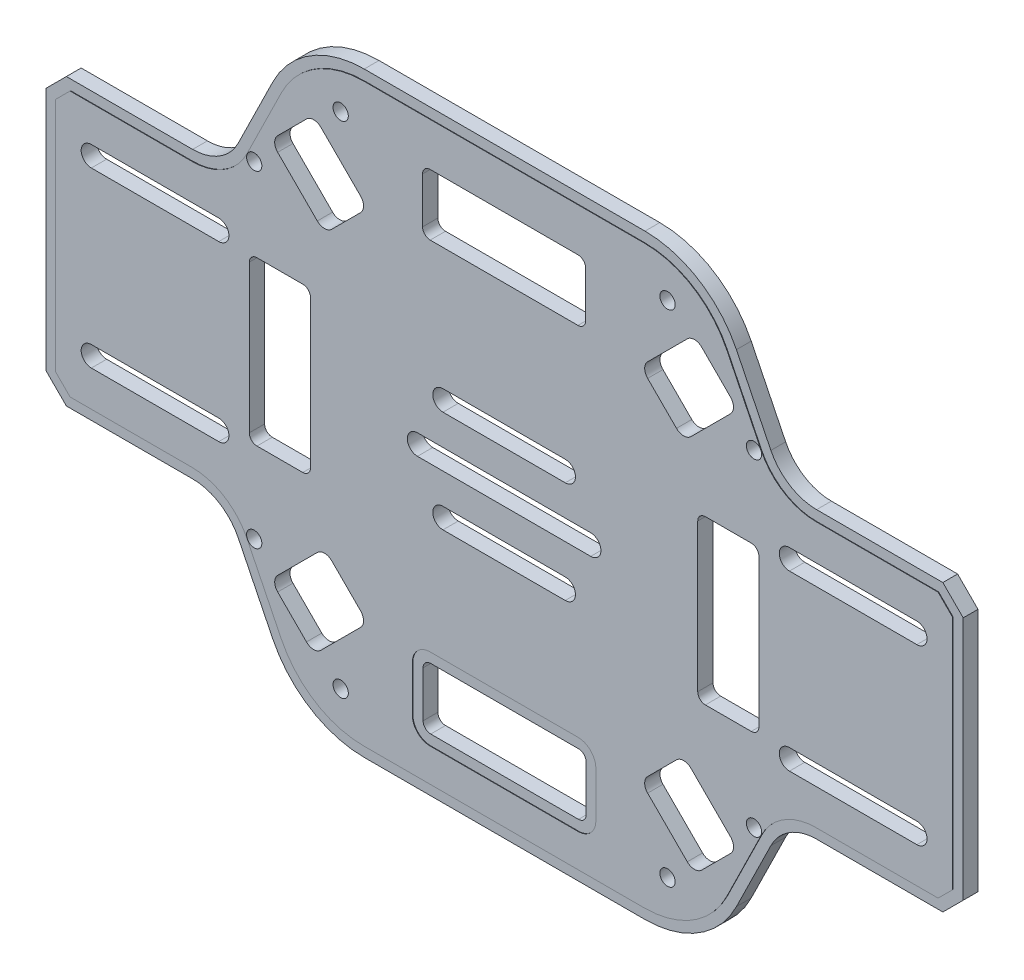
from build123d import *

# Parameters (mm, degrees)
SALIENTE_EXTRUIR1_DEPTH = 1.5
CHAFL_N1_SIZE           = 4
CORTAR_EXTRUIR1_DEPTH   = 0.1
CORTAR_EXTRUIR2_DEPTH   = 0.1
CROQUIS4_R              = 1.5
CORTAR_EXTRUIR3_DEPTH   = 24.1
CROQUIS5_R              = 1.5
CORTAR_EXTRUIR4_DEPTH   = 24.1
CORTAR_EXTRUIR5_DEPTH   = 24.1


with BuildPart() as part:
    # Croquis1 → Saliente-Extruir1 (new body, symmetric)
    with BuildSketch(Plane.XY):
        with BuildLine():
            Line((0, -28), (0, 28))
            Line((0, 28), (28.774108591, 28))
            ThreePointArc((28.774108591, 28), (34.059372749, 29.510831444), (37.747608252, 33.586803445))
            Line((37.747608252, 33.586803445), (44.504783496, 47.326393109))
            ThreePointArc((44.504783496, 47.326393109), (51.881254502, 55.478337112), (62.451782819, 58.5))
            Line((62.451782819, 58.5), (117.548217181, 58.5))
            ThreePointArc((117.548217181, 58.5), (128.118745498, 55.478337112), (135.495216504, 47.326393109))
            Line((135.495216504, 47.326393109), (142.252391748, 33.586803445))
            ThreePointArc((142.252391748, 33.586803445), (145.940627251, 29.510831444), (151.225891409, 28))
            Line((151.225891409, 28), (180, 28))
            Line((180, 28), (180, -28))
            Line((180, -28), (151.225891409, -28))
            ThreePointArc((151.225891409, -28), (145.940627251, -29.510831444), (142.252391748, -33.586803445))
            Line((142.252391748, -33.586803445), (135.495216504, -47.326393109))
            ThreePointArc((135.495216504, -47.326393109), (128.118745498, -55.478337112), (117.548217181, -58.5))
            Line((117.548217181, -58.5), (62.451782819, -58.5))
            ThreePointArc((62.451782819, -58.5), (51.881254502, -55.478337112), (44.504783496, -47.326393109))
            Line((44.504783496, -47.326393109), (37.747608252, -33.586803445))
            ThreePointArc((37.747608252, -33.586803445), (34.059372749, -29.510831444), (28.774108591, -28))
            Line((28.774108591, -28), (0, -28))
        make_face()
        with BuildLine():
            Line((78, -8), (102, -8))
            ThreePointArc((102, -8), (104, -10), (102, -12))
            Line((102, -12), (78, -12))
            ThreePointArc((78, -12), (76, -10), (78, -8))
        make_face(mode=Mode.SUBTRACT)
        with BuildLine():
            Line((107, -2), (73, -2))
            ThreePointArc((73, -2), (71, 0), (73, 2))
            Line((73, 2), (107, 2))
            ThreePointArc((107, 2), (109, 0), (107, -2))
        make_face(mode=Mode.SUBTRACT)
        with BuildLine():
            Line((78, 12), (102, 12))
            ThreePointArc((102, 12), (104, 10), (102, 8))
            Line((102, 8), (78, 8))
            ThreePointArc((78, 8), (76, 10), (78, 12))
        make_face(mode=Mode.SUBTRACT)
        with BuildLine():
            Line((106, -46.5), (106, -37.5))
            ThreePointArc((106, -37.5), (105.560660172, -36.439339828), (104.5, -36))
            Line((104.5, -36), (75.5, -36))
            ThreePointArc((75.5, -36), (74.439339828, -36.439339828), (74, -37.5))
            Line((74, -37.5), (74, -46.5))
            ThreePointArc((74, -46.5), (74.439339828, -47.560660172), (75.5, -48))
            Line((75.5, -48), (104.5, -48))
            ThreePointArc((104.5, -48), (105.560660172, -47.560660172), (106, -46.5))
        make_face(mode=Mode.SUBTRACT)
        with BuildLine():
            Line((75.5, 48), (104.5, 48))
            ThreePointArc((104.5, 48), (105.560660172, 47.560660172), (106, 46.5))
            Line((106, 46.5), (106, 37.5))
            ThreePointArc((106, 37.5), (105.560660172, 36.439339828), (104.5, 36))
            Line((104.5, 36), (75.5, 36))
            ThreePointArc((75.5, 36), (74.439339828, 36.439339828), (74, 37.5))
            Line((74, 37.5), (74, 46.5))
            ThreePointArc((74, 46.5), (74.439339828, 47.560660172), (75.5, 48))
        make_face(mode=Mode.SUBTRACT)
        with BuildLine():
            Line((40, 14.5), (40, -14.5))
            ThreePointArc((40, -14.5), (40.439339828, -15.560660172), (41.5, -16))
            Line((41.5, -16), (50.5, -16))
            ThreePointArc((50.5, -16), (51.560660172, -15.560660172), (52, -14.5))
            Line((52, -14.5), (52, 14.5))
            ThreePointArc((52, 14.5), (51.560660172, 15.560660172), (50.5, 16))
            Line((50.5, 16), (41.5, 16))
            ThreePointArc((41.5, 16), (40.439339828, 15.560660172), (40, 14.5))
        make_face(mode=Mode.SUBTRACT)
        with BuildLine():
            Line((146, -19), (171, -19))
            ThreePointArc((171, -19), (173, -17), (171, -15))
            Line((171, -15), (146, -15))
            ThreePointArc((146, -15), (144, -17), (146, -19))
        make_face(mode=Mode.SUBTRACT)
        with BuildLine():
            Line((129.5, 16), (138.5, 16))
            ThreePointArc((138.5, 16), (139.560660172, 15.560660172), (140, 14.5))
            Line((140, 14.5), (140, -14.5))
            ThreePointArc((140, -14.5), (139.560660172, -15.560660172), (138.5, -16))
            Line((138.5, -16), (129.5, -16))
            ThreePointArc((129.5, -16), (128.439339828, -15.560660172), (128, -14.5))
            Line((128, -14.5), (128, 14.5))
            ThreePointArc((128, 14.5), (128.439339828, 15.560660172), (129.5, 16))
        make_face(mode=Mode.SUBTRACT)
        with BuildLine():
            Line((146, 19), (171, 19))
            ThreePointArc((171, 19), (173, 17), (171, 15))
            Line((171, 15), (146, 15))
            ThreePointArc((146, 15), (144, 17), (146, 19))
        make_face(mode=Mode.SUBTRACT)
        with BuildLine():
            Line((34, -15), (9, -15))
            ThreePointArc((9, -15), (7, -17), (9, -19))
            Line((9, -19), (34, -19))
            ThreePointArc((34, -19), (36, -17), (34, -15))
        make_face(mode=Mode.SUBTRACT)
        with BuildLine():
            Line((34, 19), (9, 19))
            ThreePointArc((9, 19), (7, 17), (9, 15))
            Line((9, 15), (34, 15))
            ThreePointArc((34, 15), (36, 17), (34, 19))
        make_face(mode=Mode.SUBTRACT)
    extrude(amount=SALIENTE_EXTRUIR1_DEPTH, both=True)

    # Chaflán1
    chafl_n1_edges = [part.edges().sort_by_distance(p)[0] for p in [
        (180, 28, 0),
        (180, -28, 0),
        (0, -28, 0),
        (0, 28, 0),
    ]]
    chamfer(chafl_n1_edges, length=CHAFL_N1_SIZE)

    # Croquis2 → Cortar-Extruir1 (cut)
    with BuildSketch(Plane.XY.offset(1.5)):
        with BuildLine():
            Line((117.548217181, 58.5), (62.451782819, 58.5))
            ThreePointArc((62.451782819, 58.5), (51.881254502, 55.478337112), (44.504783496, 47.326393109))
            Line((44.504783496, 47.326393109), (37.747608252, 33.586803445))
            ThreePointArc((37.747608252, 33.586803445), (34.059372749, 29.510831444), (28.774108591, 28))
            Line((28.774108591, 28), (4, 28))
            Line((4, 28), (0, 24))
            Line((0, 24), (0, -24))
            Line((0, -24), (4, -28))
            Line((4, -28), (28.774108591, -28))
            ThreePointArc((28.774108591, -28), (34.059372749, -29.510831444), (37.747608252, -33.586803445))
            Line((37.747608252, -33.586803445), (44.504783496, -47.326393109))
            ThreePointArc((44.504783496, -47.326393109), (51.881254502, -55.478337112), (62.451782819, -58.5))
            Line((62.451782819, -58.5), (117.548217181, -58.5))
            ThreePointArc((117.548217181, -58.5), (128.118745498, -55.478337112), (135.495216504, -47.326393109))
            Line((135.495216504, -47.326393109), (142.252391748, -33.586803445))
            ThreePointArc((142.252391748, -33.586803445), (145.940627251, -29.510831444), (151.225891409, -28))
            Line((151.225891409, -28), (176, -28))
            Line((176, -28), (180, -24))
            Line((180, -24), (180, 24))
            Line((180, 24), (176, 28))
            Line((176, 28), (151.225891409, 28))
            ThreePointArc((151.225891409, 28), (145.940627251, 29.510831444), (142.252391748, 33.586803445))
            Line((142.252391748, 33.586803445), (135.495216504, 47.326393109))
            ThreePointArc((135.495216504, 47.326393109), (128.118745498, 55.478337112), (117.548217181, 58.5))
        make_face()
        with BuildLine():
            Line((140.457691816, 32.704164134), (133.700516571, 46.443753798))
            ThreePointArc((133.700516571, 46.443753798), (127.061692667, 53.780503401), (117.548217181, 56.5))
            Line((117.548217181, 56.5), (62.451782819, 56.5))
            ThreePointArc((62.451782819, 56.5), (52.938307333, 53.780503401), (46.299483429, 46.443753798))
            Line((46.299483429, 46.443753798), (39.542308184, 32.704164134))
            ThreePointArc((39.542308184, 32.704164134), (35.116425581, 27.812997733), (28.774108591, 26))
            Line((28.774108591, 26), (4.828427125, 26))
            Line((4.828427125, 26), (2, 23.171572875))
            Line((2, 23.171572875), (2, -23.171572875))
            Line((2, -23.171572875), (4.828427125, -26))
            Line((4.828427125, -26), (28.774108591, -26))
            ThreePointArc((28.774108591, -26), (35.116425581, -27.812997733), (39.542308184, -32.704164134))
            Line((39.542308184, -32.704164134), (46.299483429, -46.443753798))
            ThreePointArc((46.299483429, -46.443753798), (52.938307333, -53.780503401), (62.451782819, -56.5))
            Line((62.451782819, -56.5), (117.548217181, -56.5))
            ThreePointArc((117.548217181, -56.5), (127.061692667, -53.780503401), (133.700516571, -46.443753798))
            Line((133.700516571, -46.443753798), (140.457691816, -32.704164134))
            ThreePointArc((140.457691816, -32.704164134), (144.883574419, -27.812997733), (151.225891409, -26))
            Line((151.225891409, -26), (175.171572875, -26))
            Line((175.171572875, -26), (178, -23.171572875))
            Line((178, -23.171572875), (178, 23.171572875))
            Line((178, 23.171572875), (175.171572875, 26))
            Line((175.171572875, 26), (151.225891409, 26))
            ThreePointArc((151.225891409, 26), (144.883574419, 27.812997733), (140.457691816, 32.704164134))
        make_face(mode=Mode.SUBTRACT)
    extrude(amount=-CORTAR_EXTRUIR1_DEPTH, mode=Mode.SUBTRACT)

    # Croquis3 → Cortar-Extruir2 (cut)
    with BuildSketch(Plane.XY.offset(1.5)):
        with BuildLine():
            Line((72, -37.5), (72, -46.5))
            ThreePointArc((72, -46.5), (73.025126266, -48.974873734), (75.5, -50))
            Line((75.5, -50), (104.5, -50))
            ThreePointArc((104.5, -50), (106.974873734, -48.974873734), (108, -46.5))
            Line((108, -46.5), (108, -37.5))
            ThreePointArc((108, -37.5), (106.974873734, -35.025126266), (104.5, -34))
            Line((104.5, -34), (75.5, -34))
            ThreePointArc((75.5, -34), (73.025126266, -35.025126266), (72, -37.5))
        make_face()
        with BuildLine():
            Line((74, -37.5), (74, -46.5))
            ThreePointArc((74, -46.5), (74.439339828, -47.560660172), (75.5, -48))
            Line((75.5, -48), (104.5, -48))
            ThreePointArc((104.5, -48), (105.560660172, -47.560660172), (106, -46.5))
            Line((106, -46.5), (106, -37.5))
            ThreePointArc((106, -37.5), (105.560660172, -36.439339828), (104.5, -36))
            Line((104.5, -36), (75.5, -36))
            ThreePointArc((75.5, -36), (74.439339828, -36.439339828), (74, -37.5))
        make_face(mode=Mode.SUBTRACT)
    extrude(amount=-CORTAR_EXTRUIR2_DEPTH, mode=Mode.SUBTRACT)

    # Croquis4 → Cortar-Extruir3 (cut)
    with BuildSketch(Plane.XY.offset(1.5)):
        with Locations((122.072928675, 49.043491424)):
            Circle(CROQUIS4_R)
        with Locations((139.043491424, 32.072928675)):
            Circle(CROQUIS4_R)
    extrude(amount=-CORTAR_EXTRUIR3_DEPTH, mode=Mode.SUBTRACT)

    # Croquis5 → Cortar-Extruir4 (cut)
    with BuildSketch(Plane.XY.offset(1.5)):
        with Locations((139.043491424, -32.072928675)):
            Circle(CROQUIS5_R)
        with Locations((122.072928675, -49.043491424)):
            Circle(CROQUIS5_R)
        with Locations((57.927071325, -49.043491424)):
            Circle(CROQUIS5_R)
        with Locations((40.956508576, -32.072928675)):
            Circle(CROQUIS5_R)
        with Locations((40.956508576, 32.072928675)):
            Circle(CROQUIS5_R)
        with Locations((57.927071325, 49.043491424)):
            Circle(CROQUIS5_R)
    extrude(amount=-CORTAR_EXTRUIR4_DEPTH, mode=Mode.SUBTRACT)

    # Croquis6 → Cortar-Extruir5 (cut)
    with BuildSketch(Plane.XY.offset(1.5)):
        with BuildLine():
            Line((126.657353263, -28.172071889), (134.435527856, -35.950246482))
            ThreePointArc((134.435527856, -35.950246482), (135.021314294, -37.364460044), (134.435527856, -38.778673607))
            Line((134.435527856, -38.778673607), (128.778673607, -44.435527856))
            ThreePointArc((128.778673607, -44.435527856), (127.364460044, -45.021314294), (125.950246482, -44.435527856))
            Line((125.950246482, -44.435527856), (118.172071889, -36.657353263))
            ThreePointArc((118.172071889, -36.657353263), (117.586285451, -35.243139701), (118.172071889, -33.828926138))
            Line((118.172071889, -33.828926138), (123.828926138, -28.172071889))
            ThreePointArc((123.828926138, -28.172071889), (125.243139701, -27.586285451), (126.657353263, -28.172071889))
        make_face()
        with BuildLine():
            Line((118.172071889, 33.828926138), (123.828926138, 28.172071889))
            ThreePointArc((123.828926138, 28.172071889), (125.243139701, 27.586285451), (126.657353263, 28.172071889))
            Line((126.657353263, 28.172071889), (134.435527856, 35.950246482))
            ThreePointArc((134.435527856, 35.950246482), (135.021314294, 37.364460044), (134.435527856, 38.778673607))
            Line((134.435527856, 38.778673607), (128.778673607, 44.435527856))
            ThreePointArc((128.778673607, 44.435527856), (127.364460044, 45.021314294), (125.950246482, 44.435527856))
            Line((125.950246482, 44.435527856), (118.172071889, 36.657353263))
            ThreePointArc((118.172071889, 36.657353263), (117.586285451, 35.243139701), (118.172071889, 33.828926138))
        make_face()
        with BuildLine():
            Line((61.827928111, -36.657353263), (54.049753518, -44.435527856))
            ThreePointArc((54.049753518, -44.435527856), (52.635539956, -45.021314294), (51.221326393, -44.435527856))
            Line((51.221326393, -44.435527856), (45.564472144, -38.778673607))
            ThreePointArc((45.564472144, -38.778673607), (44.978685706, -37.364460044), (45.564472144, -35.950246482))
            Line((45.564472144, -35.950246482), (53.342646737, -28.172071889))
            ThreePointArc((53.342646737, -28.172071889), (54.756860299, -27.586285451), (56.171073862, -28.172071889))
            Line((56.171073862, -28.172071889), (61.827928111, -33.828926138))
            ThreePointArc((61.827928111, -33.828926138), (62.413714549, -35.243139701), (61.827928111, -36.657353263))
        make_face()
        with BuildLine():
            Line((53.342646737, 28.172071889), (45.564472144, 35.950246482))
            ThreePointArc((45.564472144, 35.950246482), (44.978685706, 37.364460044), (45.564472144, 38.778673607))
            Line((45.564472144, 38.778673607), (51.221326393, 44.435527856))
            ThreePointArc((51.221326393, 44.435527856), (52.635539956, 45.021314294), (54.049753518, 44.435527856))
            Line((54.049753518, 44.435527856), (61.827928111, 36.657353263))
            ThreePointArc((61.827928111, 36.657353263), (62.413714549, 35.243139701), (61.827928111, 33.828926138))
            Line((61.827928111, 33.828926138), (56.171073862, 28.172071889))
            ThreePointArc((56.171073862, 28.172071889), (54.756860299, 27.586285451), (53.342646737, 28.172071889))
        make_face()
    extrude(amount=-CORTAR_EXTRUIR5_DEPTH, mode=Mode.SUBTRACT)


solid = part.part
